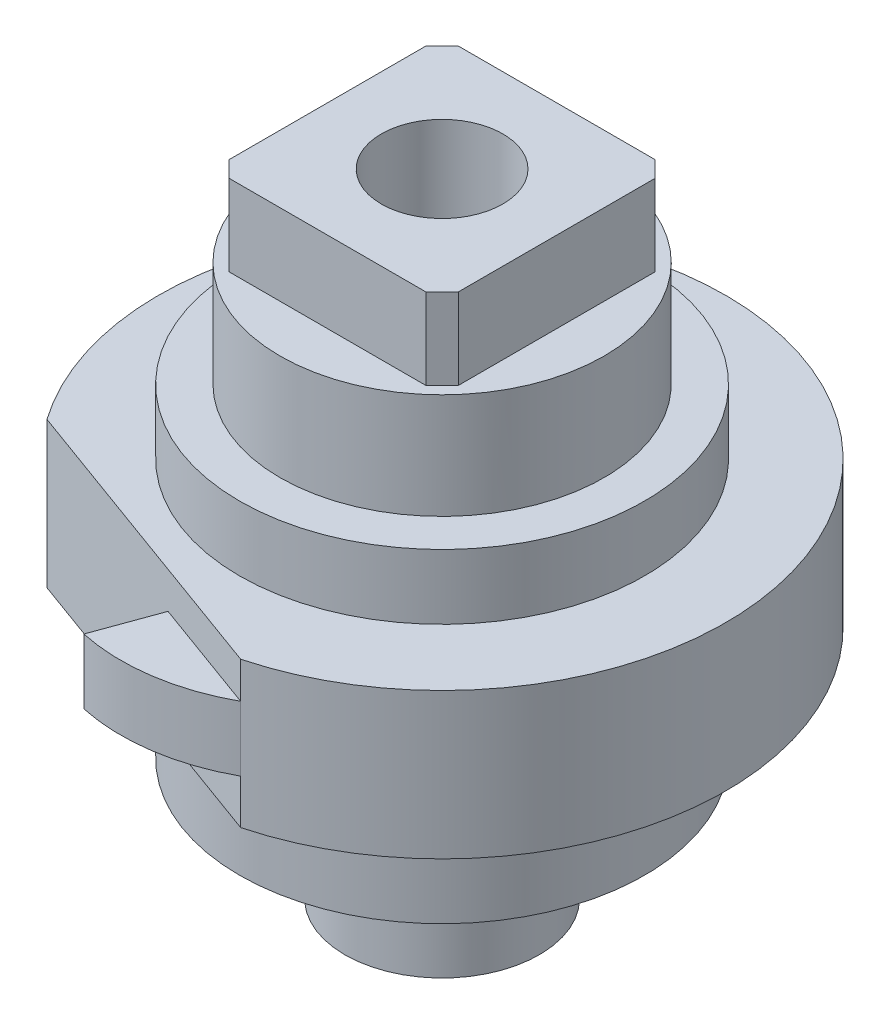
from build123d import *

# Parameters (mm, degrees)
BOSS_EXTRUDE1_DEPTH = 0.625
SKETCH2_R           = 1.25
BOSS_EXTRUDE2_DEPTH = 0.4
SKETCH3_R           = 1
BOSS_EXTRUDE3_DEPTH = 0.65
SKETCH4_W           = 1.414213562
SKETCH4_H           = 1.414213562
BOSS_EXTRUDE4_DEPTH = 0.5
BOSS_EXTRUDE5_DEPTH = 0.4
BOSS_EXTRUDE6_DEPTH = 0.275
HOLE1_D             = 0.75
HOLE1_DEPTH         = 2
CHAMFER1_SIZE       = 0.1


with BuildPart() as part:
    # Sketch1 → Boss-Extrude1 (new body)
    with BuildSketch(Plane.XZ.offset(1.025)):
        with BuildLine():
            Line((0.448503586, 1.691550925), (-1.430881656, 1.007510639))
            ThreePointArc((-1.430881656, 1.007510639), (0.598535251, -1.644462086), (0.448503586, 1.691550925))
        make_face()
    extrude(amount=-BOSS_EXTRUDE1_DEPTH)

    # Sketch2 → Boss-Extrude2 (add)
    with BuildSketch(Plane(origin=(0, -0.4, 0), x_dir=(-1, 0, 0), z_dir=(0, 1, 0))):
        Circle(SKETCH2_R)
    extrude(amount=BOSS_EXTRUDE2_DEPTH)

    # Sketch3 → Boss-Extrude3 (add)
    with BuildSketch(Plane(origin=(0, 0, 0), x_dir=(-1, 0, 0), z_dir=(0, 1, 0))):
        Circle(SKETCH3_R)
    extrude(amount=BOSS_EXTRUDE3_DEPTH)

    # Sketch4 → Boss-Extrude4 (add)
    with BuildSketch(Plane(origin=(0, 0.65, 0), x_dir=(-1, 0, 0), z_dir=(0, 1, 0))):
        Rectangle(SKETCH4_W, SKETCH4_H)
    extrude(amount=BOSS_EXTRUDE4_DEPTH)

    # Sketch5 → Boss-Extrude5 (add)
    with BuildSketch(Plane.XZ.offset(1.025)):
        with BuildLine():
            Line((-0.394915124, 1.815971484), (-0.25626588, 1.435035818))
            Line((-0.25626588, 1.435035818), (0.448503586, 1.691550925))
            ThreePointArc((0.448503586, 1.691550925), (0.038013824, 1.829816276), (-0.394915124, 1.815971484))
        make_face()
    extrude(amount=-BOSS_EXTRUDE5_DEPTH)

    # Sketch6 → Boss-Extrude6 (add)
    with BuildSketch(Plane.XZ.offset(1.025)):
        with BuildLine():
            Line((-1.430881656, 1.007510639), (0.448503586, 1.691550925))
            ThreePointArc((0.448503586, 1.691550925), (0.598535251, -1.644462086), (-1.430881656, 1.007510639))
        make_face()
    extrude(amount=BOSS_EXTRUDE6_DEPTH)

    # Sketch7 → Revolve1 (revolve)
    with BuildSketch(Plane(origin=(0, 0, 0), x_dir=(-1, 0, 0), z_dir=(0, 0, -1))):
        Polygon((-0.6, -2.75), (0, -2.75), (0, -1.3), (-1.25, -1.3), (-1.25, -2), (-0.6, -2), align=None)
    revolve(axis=Axis((0, -2.75, 0), (0, 1, 0)))

    # Hole1
    with Locations(Plane(origin=(0, 1.15, 0), x_dir=(1, 0, 0), z_dir=(0, 1, 0))):
        with Locations((0, 0)):
            Hole(HOLE1_D / 2, depth=HOLE1_DEPTH)

    # Chamfer1
    chamfer1_edges = [part.edges().sort_by_distance(p)[0] for p in [
        (-0.707106781, 0.9, 0.707106781),
        (0.707106781, 0.9, 0.707106781),
        (0.707106781, 0.9, -0.707106781),
        (-0.707106781, 0.9, -0.707106781),
    ]]
    chamfer(chamfer1_edges, length=CHAMFER1_SIZE)


solid = part.part
